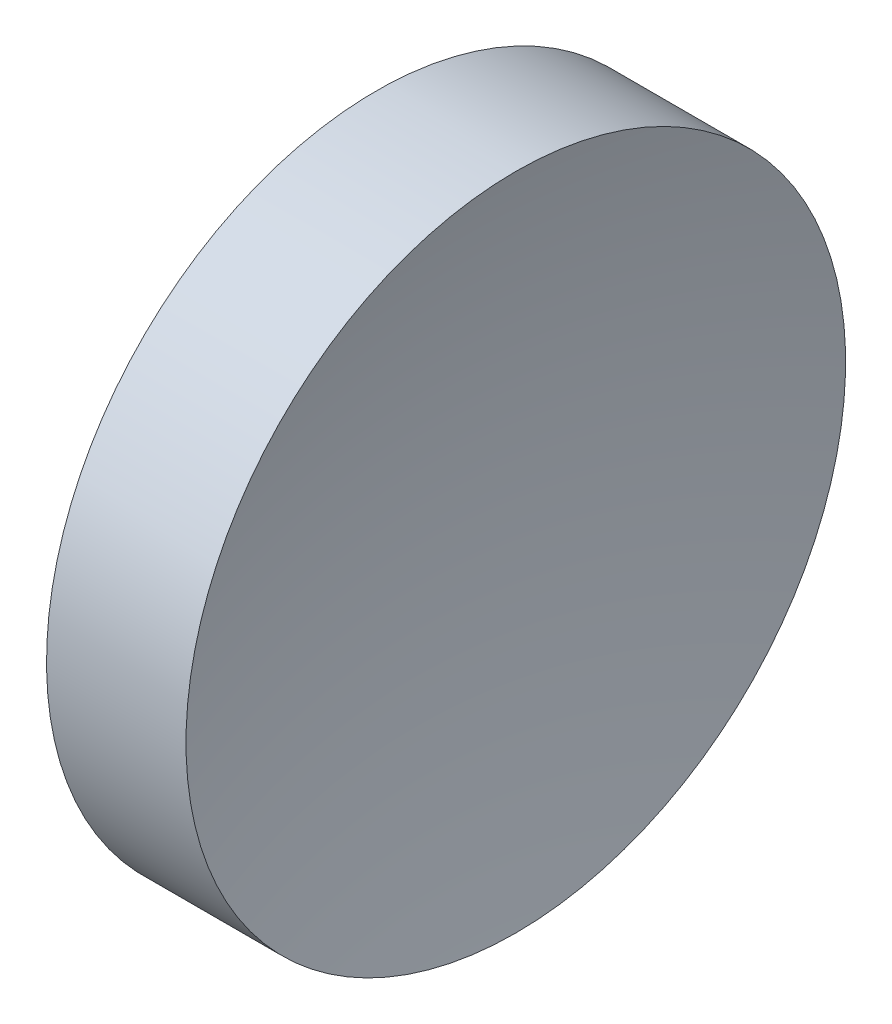
from build123d import *


with BuildPart() as part:
    # 草图1 → 旋转1 (revolve)
    with BuildSketch(Plane.XY):
        with BuildLine():
            Line((22.424232054, 13.031126091), (22.424232054, 18.031126091))
            Line((22.424232054, 18.031126091), (24.538701115, 18.031126091))
            ThreePointArc((24.538701115, 18.031126091), (24.078424996, 15.549933956), (23.924232054, 13.031126091))
            Line((23.924232054, 13.031126091), (22.424232054, 13.031126091))
        make_face()
    revolve(axis=Axis((21.505975118, 13.031126091, 0), (1, 0, 0)))


solid = part.part
